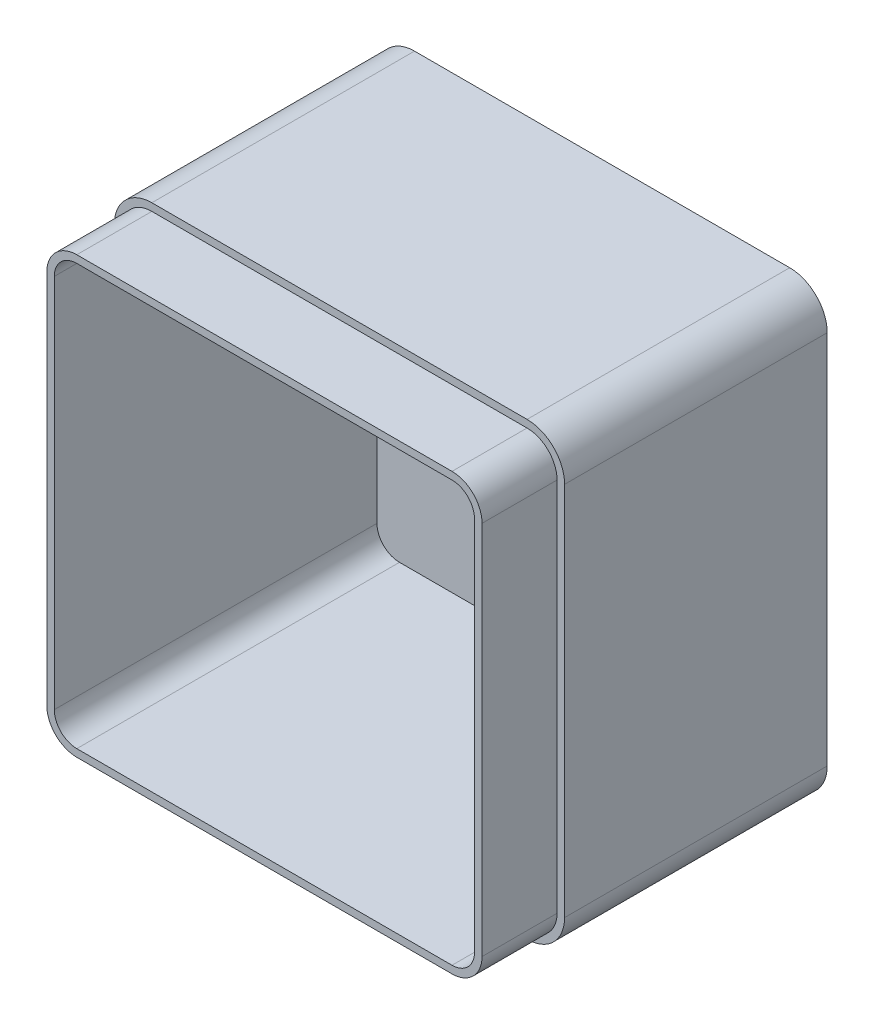
from build123d import *

# Parameters (mm, degrees)
SKETCH1_W           = 120
SKETCH1_H           = 120
BOSS_EXTRUDE1_DEPTH = 90
FILLET1_R           = 10
SHELL1_T            = -4
CUT_EXTRUDE3_DEPTH  = 20


with BuildPart() as part:
    # Sketch1 → Boss-Extrude1 (new body)
    with BuildSketch(Plane.XY):
        with Locations((60, 60)):
            Rectangle(SKETCH1_W, SKETCH1_H)
    extrude(amount=BOSS_EXTRUDE1_DEPTH)

    # Fillet1
    fillet1_edges = [part.edges().sort_by_distance(p)[0] for p in [
        (0, 120, 45),
        (120, 120, 45),
        (120, 0, 45),
        (0, 0, 45),
    ]]
    fillet(fillet1_edges, radius=FILLET1_R)

    # Shell1
    shell1_openings = [part.faces().sort_by_distance(p)[0] for p in [
        (60, 60, 90),
    ]]
    offset(amount=SHELL1_T, openings=shell1_openings, kind=Kind.INTERSECTION)

    # Sketch3 → Cut-Extrude3 (cut)
    with BuildSketch(Plane.XY.offset(90)):
        with BuildLine():
            Line((0, 110), (0, 10))
            ThreePointArc((0, 10), (2.928932188, 2.928932188), (10, 0))
            Line((10, 0), (110, 0))
            ThreePointArc((110, 0), (117.071067812, 2.928932188), (120, 10))
            Line((120, 10), (120, 110))
            ThreePointArc((120, 110), (117.071067812, 117.071067812), (110, 120))
            Line((110, 120), (10, 120))
            ThreePointArc((10, 120), (2.928932188, 117.071067812), (0, 110))
        make_face()
        with BuildLine():
            Line((2, 110), (2, 10))
            ThreePointArc((2, 10), (4.343145751, 4.343145751), (10, 2))
            Line((10, 2), (110, 2))
            ThreePointArc((110, 2), (115.656854249, 4.343145751), (118, 10))
            Line((118, 10), (118, 110))
            ThreePointArc((118, 110), (115.656854249, 115.656854249), (110, 118))
            Line((110, 118), (10, 118))
            ThreePointArc((10, 118), (4.343145751, 115.656854249), (2, 110))
        make_face(mode=Mode.SUBTRACT)
    extrude(amount=-CUT_EXTRUDE3_DEPTH, mode=Mode.SUBTRACT)


solid = part.part
